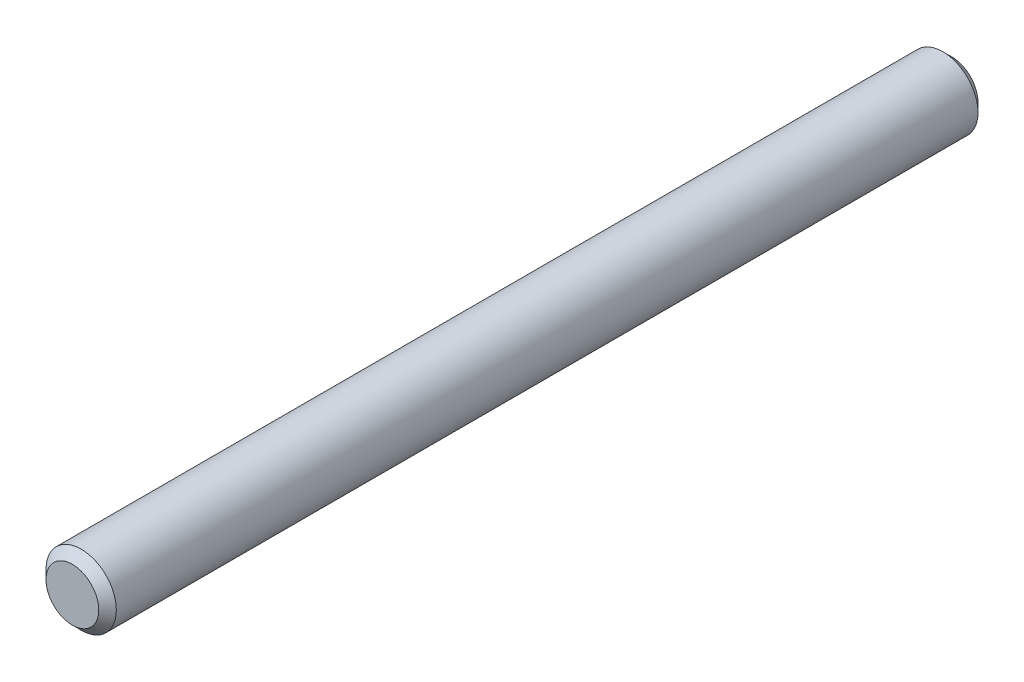
from build123d import *

# Parameters (mm, degrees)
SKETCH1_R           = 2
BOSS_EXTRUDE1_DEPTH = 25
CHAMFER1_SIZE       = 0.5


with BuildPart() as part:
    # Sketch1 → Boss-Extrude1 (new body, symmetric)
    with BuildSketch(Plane.XY):
        Circle(SKETCH1_R)
    extrude(amount=BOSS_EXTRUDE1_DEPTH, both=True)

    # Chamfer1
    chamfer1_edges = [part.edges().sort_by_distance(p)[0] for p in [
        (-2, 0, -25),
        (-2, 0, 25),
    ]]
    chamfer(chamfer1_edges, length=CHAMFER1_SIZE)


solid = part.part
